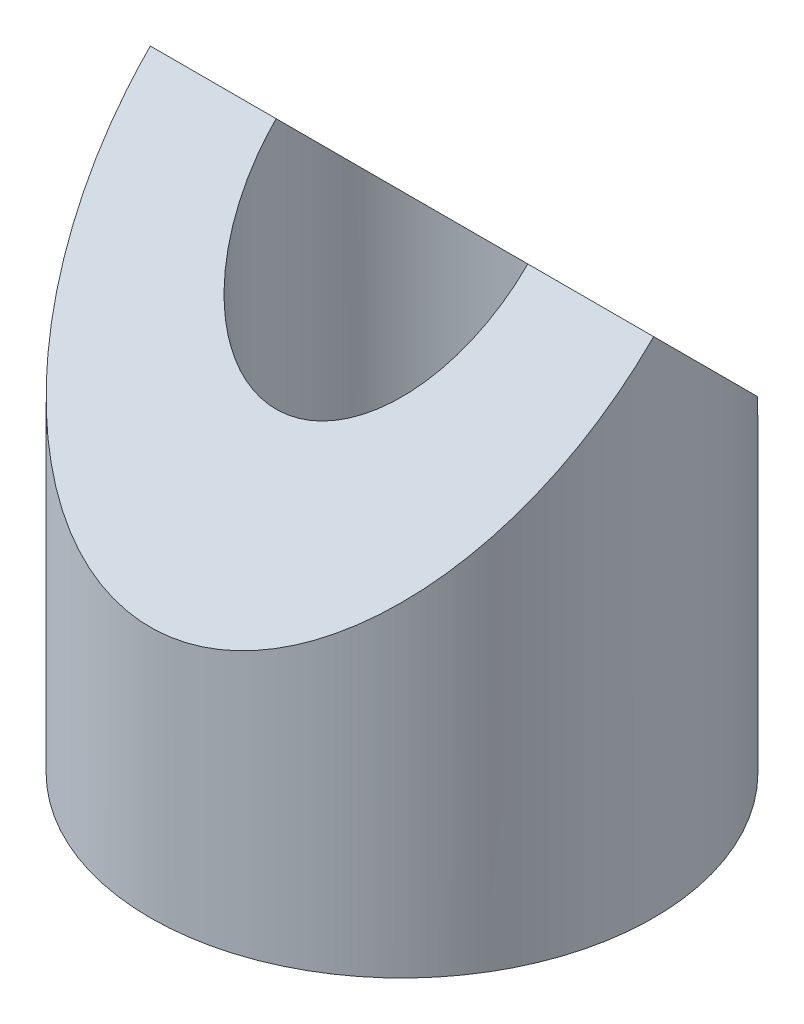
from build123d import *

# Parameters (mm, degrees)
SKETCH1_R           = 2
SKETCH1_R_2         = 1
BOSS_EXTRUDE1_DEPTH = 4
CUT_EXTRUDE1_DEPTH  = 2


with BuildPart() as part:
    # Sketch1 → Boss-Extrude1 (new body)
    with BuildSketch(Plane(origin=(0, 0, 0), x_dir=(1, 0, 0), z_dir=(0, 1, 0))):
        Circle(SKETCH1_R)
        Circle(SKETCH1_R_2, mode=Mode.SUBTRACT)
    extrude(amount=BOSS_EXTRUDE1_DEPTH)

    # Sketch2 → Cut-Extrude1 (cut, symmetric)
    with BuildSketch(Plane(origin=(0, 0, 0), x_dir=(0, 0, -1), z_dir=(1, 0, 0))):
        Polygon((2, 4), (0, 4), (2, 2), align=None)
        Polygon((-2, 4), (-2, 2), (0, 4), align=None)
    extrude(amount=CUT_EXTRUDE1_DEPTH, both=True, mode=Mode.SUBTRACT)


solid = part.part
